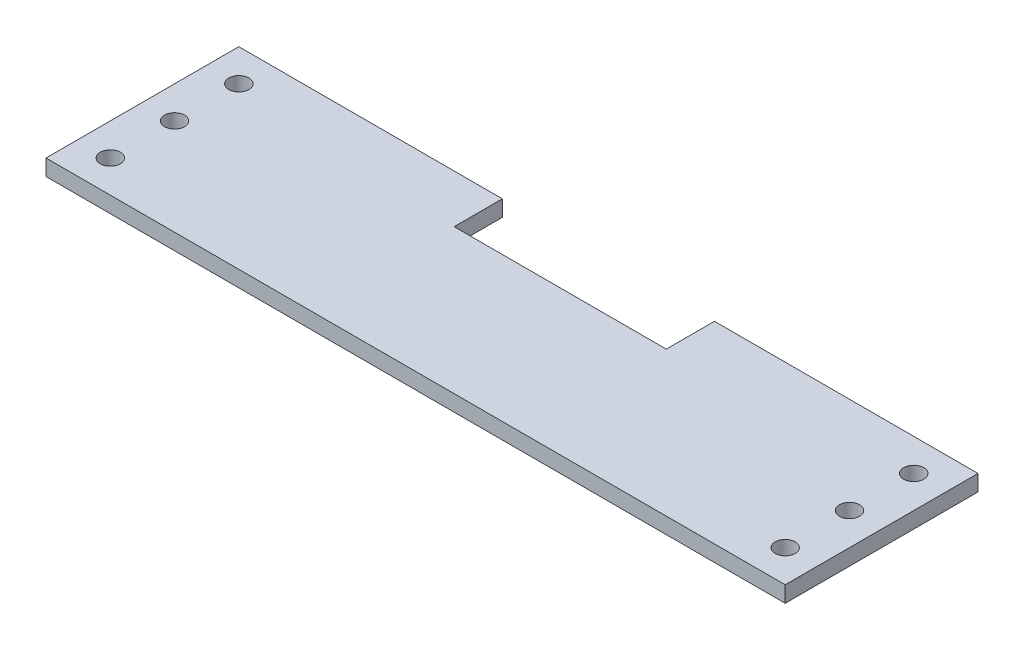
from build123d import *

# Parameters (mm, degrees)
SKETCH1_W                     = 292.1
SKETCH1_H                     = 76.2
SKETCH1_R                     = 3.96875
BOSS_EXTRUDE1_DEPTH           = 6.35
MASTER_CYLINDER_OPENING_REACH = 8.35
SKETCH2_W                     = 83.82
SKETCH2_H                     = 19.05


with BuildPart() as part:
    # Sketch1 → Boss-Extrude1 (new body)
    with BuildSketch(Plane(origin=(0, 0, 0), x_dir=(1, 0, 0), z_dir=(0, 1, 0))):
        with Locations((146.05, 38.1)):
            Rectangle(SKETCH1_W, SKETCH1_H)
        with Locations((12.7, 63.5)):
            Circle(SKETCH1_R, mode=Mode.SUBTRACT)
        with Locations((12.7, 38.1)):
            Circle(SKETCH1_R, mode=Mode.SUBTRACT)
        with Locations((12.7, 12.7)):
            Circle(SKETCH1_R, mode=Mode.SUBTRACT)
        with Locations((279.4, 12.7)):
            Circle(SKETCH1_R, mode=Mode.SUBTRACT)
        with Locations((279.4, 38.1)):
            Circle(SKETCH1_R, mode=Mode.SUBTRACT)
        with Locations((279.4, 63.5)):
            Circle(SKETCH1_R, mode=Mode.SUBTRACT)
    extrude(amount=BOSS_EXTRUDE1_DEPTH)

    # Sketch2 → Master Cylinder Opening (cut, up to next)
    with BuildSketch(Plane(origin=(0, 6.35, 0), x_dir=(1, 0, 0), z_dir=(0, 1, 0)), mode=Mode.PRIVATE) as master_cylinder_opening_sk1:
        with Locations((146.05, 66.675)):
            Rectangle(SKETCH2_W, SKETCH2_H)
    master_cylinder_opening_tool1 = extrude(master_cylinder_opening_sk1.sketch, amount=-MASTER_CYLINDER_OPENING_REACH, mode=Mode.PRIVATE) & part.part
    add(master_cylinder_opening_tool1.solids().sort_by_distance((146.05, 6.35, -66.675))[0], mode=Mode.SUBTRACT)


solid = part.part
